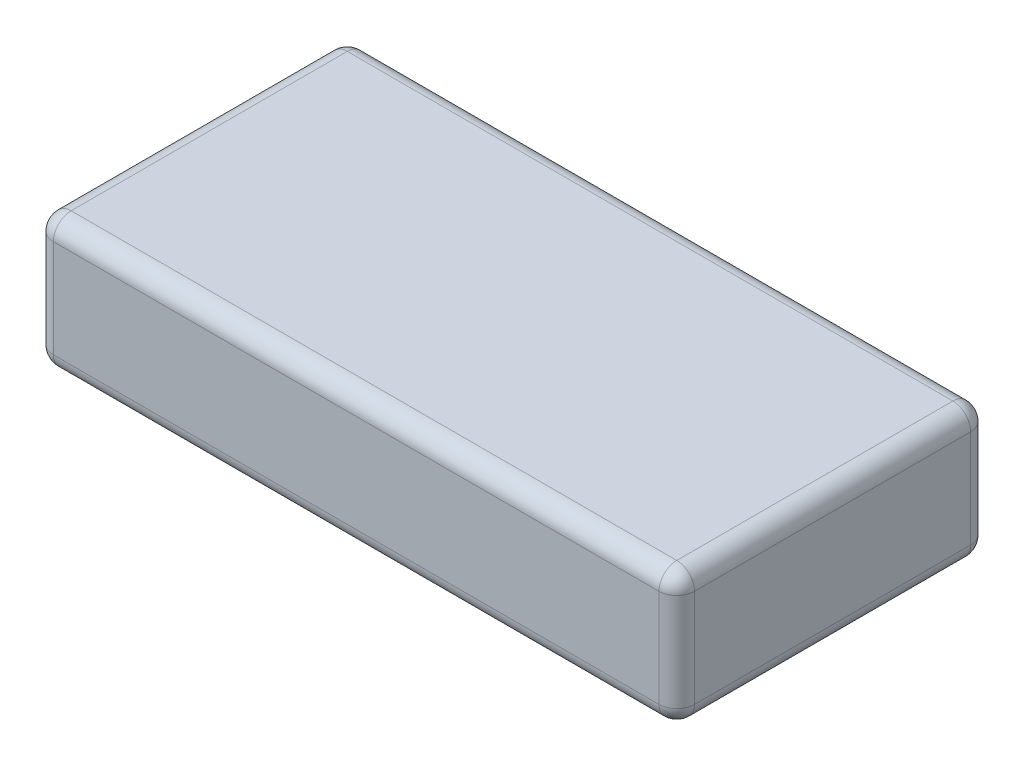
from build123d import *

# Parameters (mm, degrees)
SKETCH1_W           = 72
SKETCH1_H           = 35
BOSS_EXTRUDE1_DEPTH = 15
FILLET1_R           = 2


with BuildPart() as part:
    # Sketch1 → Boss-Extrude1 (new body)
    with BuildSketch(Plane(origin=(0, 0, 0), x_dir=(1, 0, 0), z_dir=(0, 1, 0))):
        Rectangle(SKETCH1_W, SKETCH1_H)
    extrude(amount=BOSS_EXTRUDE1_DEPTH)

    # Fillet1
    fillet1_edges = [part.edges().sort_by_distance(p)[0] for p in [
        (36, 15, 0),
        (0, 15, -17.5),
        (-36, 15, 0),
        (0, 0, -17.5),
        (36, 0, 0),
        (0, 0, 17.5),
        (-36, 0, 0),
        (-36, 7.5, -17.5),
        (36, 7.5, -17.5),
        (36, 7.5, 17.5),
        (-36, 7.5, 17.5),
        (0, 15, 17.5),
    ]]
    fillet(fillet1_edges, radius=FILLET1_R)


solid = part.part
